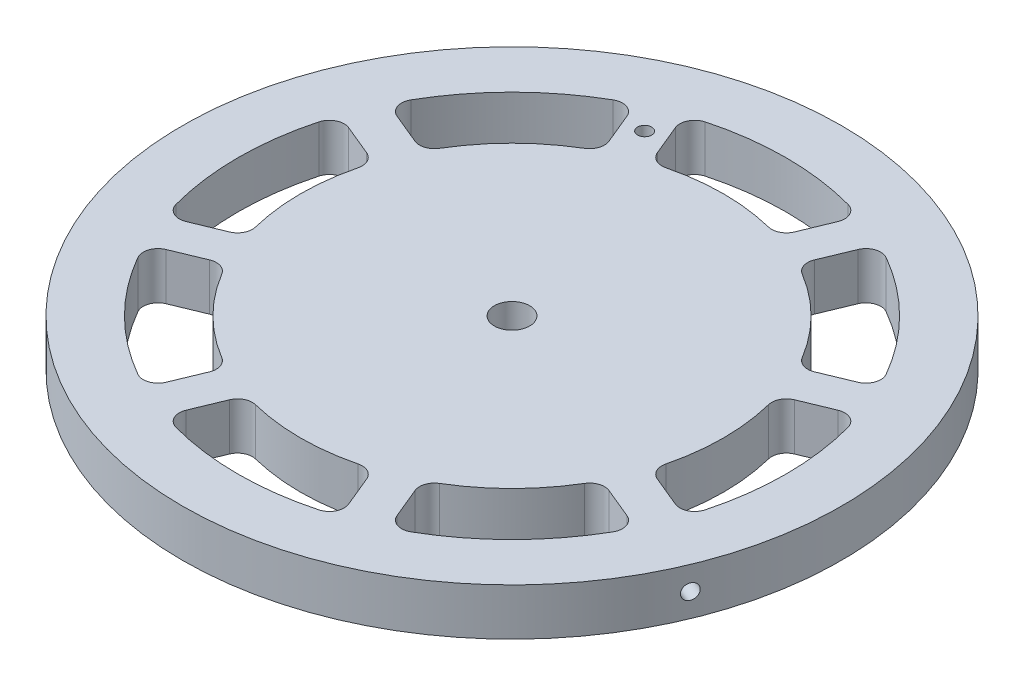
from build123d import *

# Parameters (mm, degrees)
SKETCH2_W                = 89.05
SKETCH2_H                = 12.7
F_10_24_TAPPED_HOLE2_D   = 3.7973
CUT_EXTRUDE1_DEPTH       = 13.7
FILLET1_R                = 4
CIRPATTERN4_COUNT        = 8
FILLET1_OF_CIRPATTERN4_R = 4
SKETCH15_W               = 2.0447
SKETCH15_H               = 116.349432022
SKETCH22_R               = 4.765
CUT_EXTRUDE4_DEPTH       = 12.8


with BuildPart() as part:
    # Sketch2 → Revolve1 (revolve)
    with BuildSketch(Plane(origin=(0, 0, 0), x_dir=(0, 0, -1), z_dir=(1, 0, 0))):
        with Locations((-44.525, 6.35)):
            Rectangle(SKETCH2_W, SKETCH2_H)
    revolve(axis=Axis((0, -0.888756804, 0), (0, 1, 0)))

    # #10-24 Tapped Hole2 (through all)
    with Locations(Plane(origin=(0, 12.7, 0), x_dir=(1, 0, 0), z_dir=(0, 1, 0))):
        with Locations((-25.333643223, 61.160825052)):
            Hole(F_10_24_TAPPED_HOLE2_D / 2)

    # Sketch8 → Cut-Extrude1 (cut, through all)
    with BuildSketch(Plane(origin=(0, 12.7, 0), x_dir=(1, 0, 0), z_dir=(0, 1, 0))):
        with BuildLine():
            Line((-17.167098173, 54.510670885), (-23.653637882, 70.170563023))
            ThreePointArc((-23.653637882, 70.170563023), (0, 74.05), (23.653637882, 70.170563023))
            Line((23.653637882, 70.170563023), (17.167098173, 54.510670885))
            ThreePointArc((17.167098173, 54.510670885), (0, 57.15), (-17.167098173, 54.510670885))
        make_face()
    cut_extrude1 = extrude(amount=-CUT_EXTRUDE1_DEPTH, mode=Mode.SUBTRACT)

    # Fillet1
    fillet1_edges = [part.edges().sort_by_distance(p)[0] for p in [
        (17.167098173, 6.35, -54.510670885),
        (-17.167098173, 6.35, -54.510670885),
        (-23.653637882, 6.35, -70.170563023),
        (23.653637882, 6.35, -70.170563023),
    ]]
    fillet(fillet1_edges, radius=FILLET1_R)

    # CirPattern4: Cut-Extrude1 ×8 about axis
    cirpattern4_axis = Axis((0, 0, 0), (0, 1, 0))
    for i in range(1, CIRPATTERN4_COUNT):
        add(cut_extrude1.rotate(cirpattern4_axis, i * 360 / CIRPATTERN4_COUNT), mode=Mode.SUBTRACT)

    # Fillet1 of CirPattern4
    fillet1_of_cirpattern4_edges = [part.edges().sort_by_distance(p)[0] for p in [
        (-26.405893498, 6.35, -50.683836561),
        (-50.683836561, 6.35, -26.405893498),
        (-66.343728699, 6.35, -32.892433207),
        (-32.892433207, 6.35, -66.343728699),
        (-54.510670885, 6.35, -17.167098173),
        (-54.510670885, 6.35, 17.167098173),
        (-70.170563023, 6.35, 23.653637882),
        (-70.170563023, 6.35, -23.653637882),
        (-50.683836561, 6.35, 26.405893498),
        (-26.405893498, 6.35, 50.683836561),
        (-32.892433207, 6.35, 66.343728699),
        (-66.343728699, 6.35, 32.892433207),
        (-17.167098173, 6.35, 54.510670885),
        (17.167098173, 6.35, 54.510670885),
        (23.653637882, 6.35, 70.170563023),
        (-23.653637882, 6.35, 70.170563023),
        (26.405893498, 6.35, 50.683836561),
        (50.683836561, 6.35, 26.405893498),
        (66.343728699, 6.35, 32.892433207),
        (32.892433207, 6.35, 66.343728699),
        (54.510670885, 6.35, 17.167098173),
        (54.510670885, 6.35, -17.167098173),
        (70.170563023, 6.35, -23.653637882),
        (70.170563023, 6.35, 23.653637882),
        (50.683836561, 6.35, -26.405893498),
        (26.405893498, 6.35, -50.683836561),
        (32.892433207, 6.35, -66.343728699),
        (66.343728699, 6.35, -32.892433207),
    ]]
    fillet(fillet1_of_cirpattern4_edges, radius=FILLET1_OF_CIRPATTERN4_R)

    # Sketch15 → #20 (0.161) Diameter Hole1 (revolve, cut)
    with BuildSketch(Plane(origin=(0, 6.35, 0), x_dir=(-0.382683432, 0, 0.923879533), z_dir=(0, 1, 0))):
        with Locations((1.02235, 58.174716011)):
            Rectangle(SKETCH15_W, SKETCH15_H)
    revolve(axis=Axis((-5.866635031, 6.35, -2.430039796), (0.923879533, 0, 0.382683432)), mode=Mode.SUBTRACT)

    # Sketch22 → Cut-Extrude4 (cut)
    with BuildSketch(Plane(origin=(0, 12.7, 0), x_dir=(1, 0, 0), z_dir=(0, 1, 0))):
        Circle(SKETCH22_R)
    extrude(amount=-CUT_EXTRUDE4_DEPTH, mode=Mode.SUBTRACT)


solid = part.part
